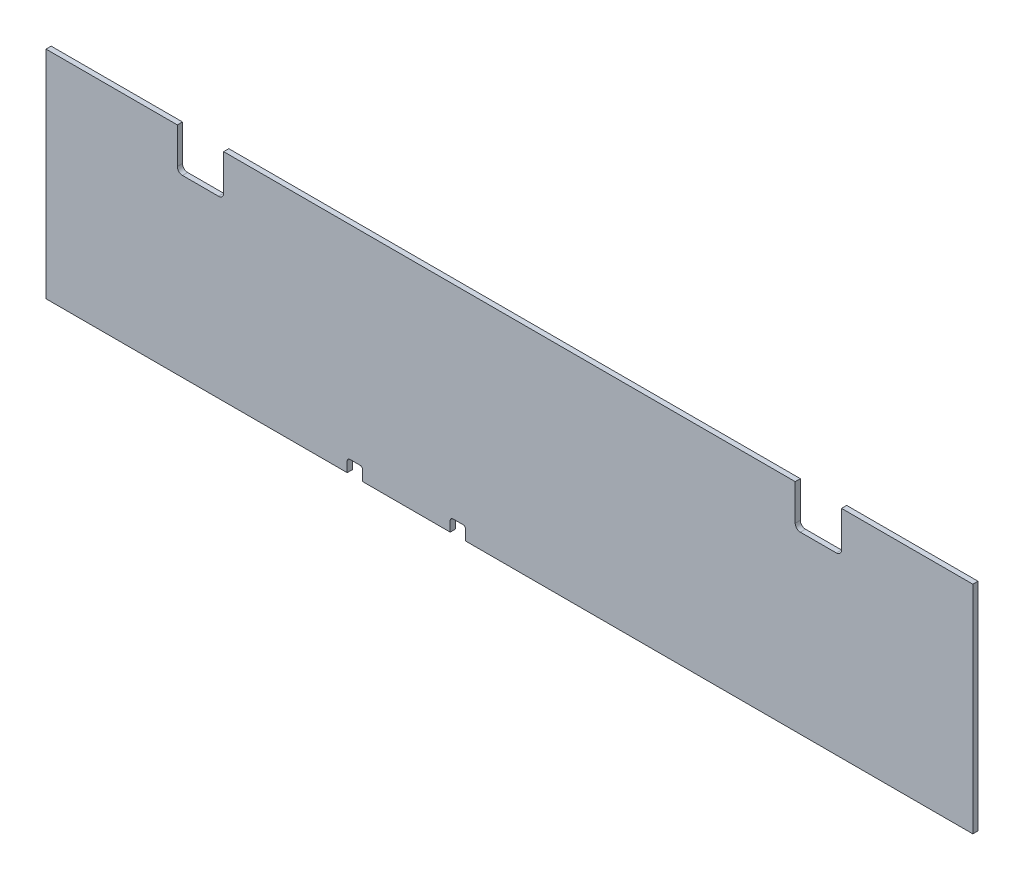
from build123d import *

# Parameters (mm, degrees)
BOSS_EXTRUDE1_DEPTH = 6.35
FILLET1_R           = 6.35
SKETCH2_W           = 19.05
SKETCH2_H           = 15.875
CUT_EXTRUDE1_DEPTH  = 7.35
FILLET2_R           = 3.175


with BuildPart() as part:
    # Sketch1 → Boss-Extrude1 (new body)
    with BuildSketch(Plane.XY):
        Polygon((0, 0), (0, 266.7), (161.925, 266.7), (161.925, 215.9), (219.075, 215.9), (219.075, 266.7), (923.925, 266.7), (923.925, 215.9), (981.075, 215.9), (981.075, 266.7), (1143, 266.7), (1143, 0), align=None)
    extrude(amount=BOSS_EXTRUDE1_DEPTH)

    # Fillet1
    fillet1_edges = [part.edges().sort_by_distance(p)[0] for p in [
        (161.925, 215.9, 3.175),
        (219.075, 215.9, 3.175),
        (923.925, 215.9, 3.175),
        (981.075, 215.9, 3.175),
    ]]
    fillet(fillet1_edges, radius=FILLET1_R)

    # Sketch2 → Cut-Extrude1 (cut, through all)
    with BuildSketch(Plane.XY.offset(6.35)):
        with Locations((381, 7.9375)):
            Rectangle(SKETCH2_W, SKETCH2_H)
        with Locations((508, 7.9375)):
            Rectangle(SKETCH2_W, SKETCH2_H)
    extrude(amount=-CUT_EXTRUDE1_DEPTH, mode=Mode.SUBTRACT)

    # Fillet2
    fillet2_edges = [part.edges().sort_by_distance(p)[0] for p in [
        (371.475, 15.875, 3.175),
        (390.525, 15.875, 3.175),
        (498.475, 15.875, 3.175),
        (517.525, 15.875, 3.175),
    ]]
    fillet(fillet2_edges, radius=FILLET2_R)


solid = part.part
